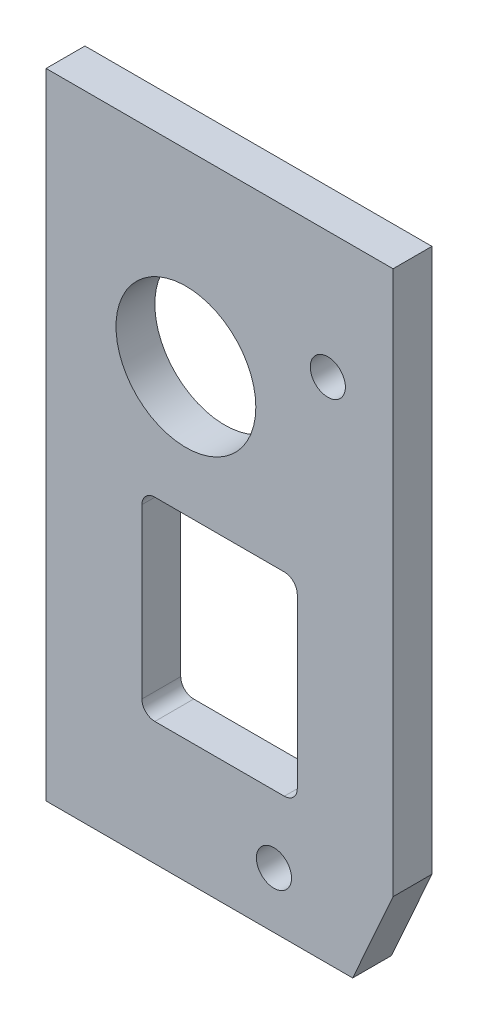
from build123d import *

# Parameters (mm, degrees)
SKETCH1_W             = 19.05
SKETCH1_H             = 23.8125
BOSS_EXTRUDE1_DEPTH   = 4.7625
SKETCH6_R             = 8.5725
CUT_EXTRUDE4_DEPTH    = 5.7625
F_6_CLEARANCE_HOLE1_D = 4.3053
FILLET1_R             = 1.5875


with BuildPart() as part:
    # Sketch1 → Boss-Extrude1 (new body)
    with BuildSketch(Plane.XY):
        Polygon((1.5875, -17.78), (1.5875, -95.5675), (39.1795, -95.5675), (44.1325, -84.455), (44.1325, -17.78), align=None)
        with Locations((22.86, -68.54825)):
            Rectangle(SKETCH1_W, SKETCH1_H, mode=Mode.SUBTRACT)
    extrude(amount=BOSS_EXTRUDE1_DEPTH)

    # Sketch6 → Cut-Extrude4 (cut, through all)
    with BuildSketch(Plane(origin=(156.406140968, -462.385138809, 4.7625), x_dir=(1, 0, 0), z_dir=(0, 0, 1))):
        with Locations((-137.673640968, 421.491138809)):
            Circle(SKETCH6_R)
    extrude(amount=-CUT_EXTRUDE4_DEPTH, mode=Mode.SUBTRACT)

    # #6 Clearance Hole1 (through all)
    with Locations(Plane.XY.offset(4.7625)):
        with Locations((36.1315, -33.274), (29.5275, -88.7095)):
            Hole(F_6_CLEARANCE_HOLE1_D / 2)

    # Fillet1
    fillet1_edges = [part.edges().sort_by_distance(p)[0] for p in [
        (13.335, -80.4545, 2.38125),
        (32.385, -80.4545, 2.38125),
        (32.385, -56.642, 2.38125),
        (13.335, -56.642, 2.38125),
    ]]
    fillet(fillet1_edges, radius=FILLET1_R)


solid = part.part
